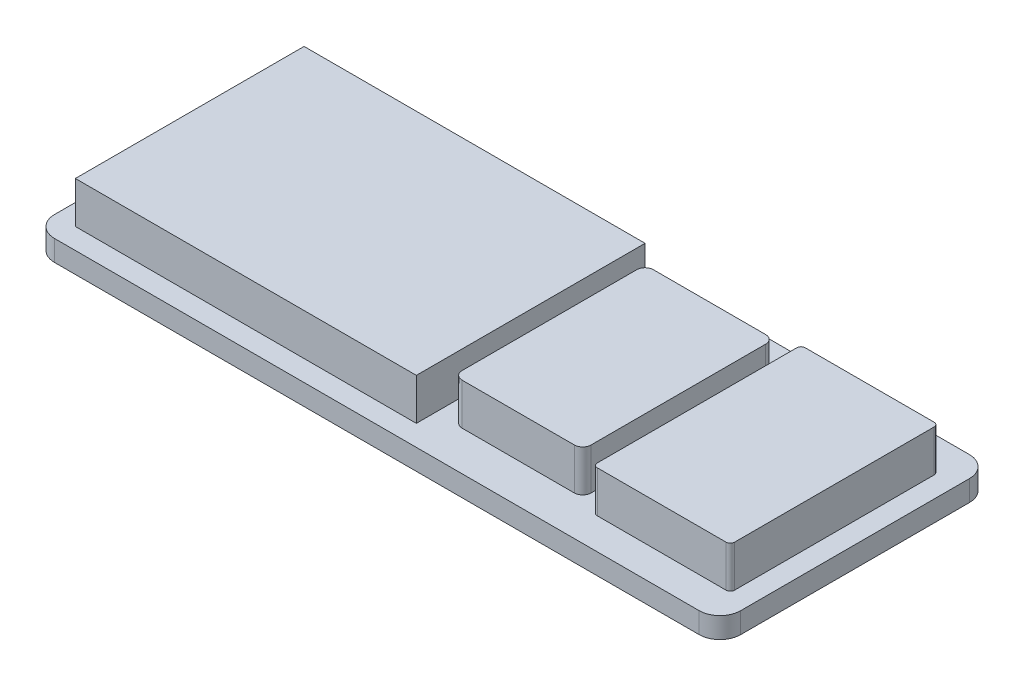
from build123d import *

# Parameters (mm, degrees)
SKETCH1_W           = 165
SKETCH1_H           = 65
BOSS_EXTRUDE1_DEPTH = 5
FILLET1_R           = 5
SKETCH2_W           = 82
SKETCH2_H           = 55
SKETCH2_W_2         = 31
SKETCH2_H_2         = 46
SKETCH2_W_3         = 33
SKETCH2_H_3         = 50
BOSS_EXTRUDE2_DEPTH = 10
FILLET2_R           = 2
FILLET3_R           = 1


with BuildPart() as part:
    # Sketch1 → Boss-Extrude1 (new body)
    with BuildSketch(Plane(origin=(0, 0, 0), x_dir=(1, 0, 0), z_dir=(0, 1, 0))):
        with Locations((17.474934091, 0)):
            Rectangle(SKETCH1_W, SKETCH1_H)
    extrude(amount=BOSS_EXTRUDE1_DEPTH)

    # Fillet1
    fillet1_edges = [part.edges().sort_by_distance(p)[0] for p in [
        (-65.025065909, 2.5, -32.5),
        (99.974934091, 2.5, -32.5),
        (99.974934091, 2.5, 32.5),
        (-65.025065909, 2.5, 32.5),
    ]]
    fillet(fillet1_edges, radius=FILLET1_R)

    # Sketch2 → Boss-Extrude2 (add)
    with BuildSketch(Plane(origin=(0, 5, 0), x_dir=(1, 0, 0), z_dir=(0, 1, 0))):
        with Locations((-19.025065909, 0)):
            Rectangle(SKETCH2_W, SKETCH2_H)
        with Locations((41.974934091, 0)):
            Rectangle(SKETCH2_W_2, SKETCH2_H_2)
        with Locations((78.474934091, 0)):
            Rectangle(SKETCH2_W_3, SKETCH2_H_3)
    extrude(amount=BOSS_EXTRUDE2_DEPTH)

    # Fillet2
    fillet2_edges = [part.edges().sort_by_distance(p)[0] for p in [
        (26.474934091, 10, -23),
        (26.474934091, 10, 23),
        (57.474934091, 10, 23),
        (57.474934091, 10, -23),
    ]]
    fillet(fillet2_edges, radius=FILLET2_R)

    # Fillet3
    fillet3_edges = [part.edges().sort_by_distance(p)[0] for p in [
        (61.974934091, 10, -25),
        (61.974934091, 10, 25),
        (94.974934091, 10, 25),
        (94.974934091, 10, -25),
    ]]
    fillet(fillet3_edges, radius=FILLET3_R)


solid = part.part
